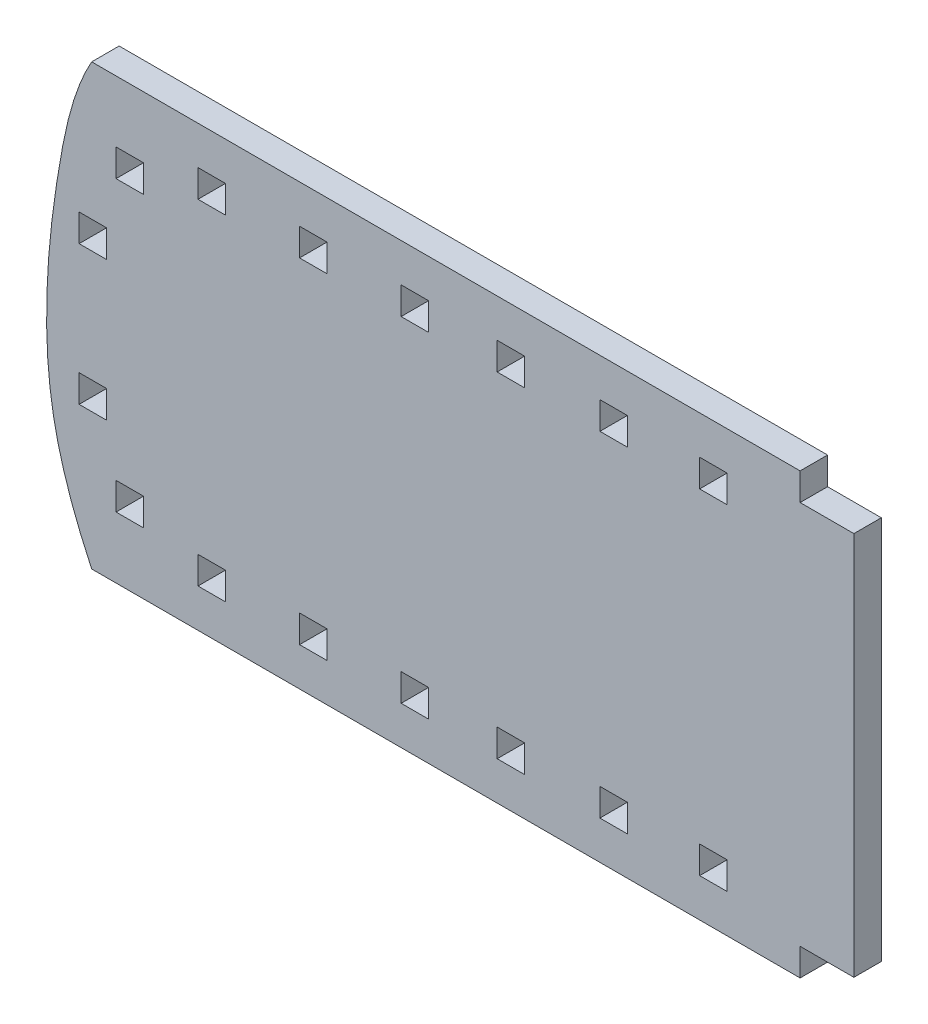
from build123d import *

# Parameters (mm, degrees)
BOSS_EXTRUDE1_DEPTH = 3.175
CUT_EXTRUDE1_DEPTH  = 3.175
SKETCH3_W           = 3.175
SKETCH3_H           = 3.175
CUT_EXTRUDE2_DEPTH  = 3.175
SKETCH4_W           = 9.525
SKETCH4_H           = 44.45
CUT_EXTRUDE3_DEPTH  = 3.175
CUT_EXTRUDE4_DEPTH  = 3.175


with BuildPart() as part:
    # Sketch1 → Boss-Extrude1 (new body)
    with BuildSketch(Plane.XY):
        with BuildLine():
            Line((47.738161277, 0), (129.678020066, 0))
            Line((129.678020066, 0), (129.678020066, -3.175))
            Line((129.678020066, -3.175), (145.421593995, -3.175))
            Line((145.421593995, -3.175), (145.421593995, -47.625))
            Line((145.421593995, -47.625), (129.678020066, -47.625))
            Line((129.678020066, -47.625), (129.678020066, -51.488987453))
            Line((129.678020066, -51.488987453), (47.738161277, -50.8))
            add(Edge.make_bspline(
                [(47.738161277, 0), (41.393133439, -1.711069928), (30.530442831, -9.367517151), (28.681444031, -25.622801065), (30.401296487, -42.131760993), (41.721917061, -48.493240739), (47.738161277, -50.8)],
                knots=[0, 0, 0, 0, 0.298782405, 0.512668788, 0.698134952, 1, 1, 1, 1], degree=3))
        make_face()
    extrude(amount=BOSS_EXTRUDE1_DEPTH)

    # Sketch2 → Cut-Extrude1 (cut)
    with BuildSketch(Plane.XY.offset(3.175)):
        with BuildLine():
            Line((47.738161277, 0), (25.94415126, 0))
            Line((25.94415126, 0), (25.94415126, -50.8))
            Line((25.94415126, -50.8), (47.738161277, -50.8))
            add(Edge.make_bspline(
                [(47.738161277, 0), (45.681525529, -3.647242432), (43.645083007, -12.887655636), (42.176101449, -25.699616702), (42.981732395, -39.048066027), (45.802728015, -46.725242417), (47.738161277, -50.8)],
                knots=[0, 0, 0, 0, 0.238683845, 0.536924902, 0.740325465, 1, 1, 1, 1], degree=3))
        make_face()
    extrude(amount=-CUT_EXTRUDE1_DEPTH, mode=Mode.SUBTRACT)

    # Sketch3 → Cut-Extrude2 (cut)
    with BuildSketch(Plane.XY.offset(3.175)):
        with Locations((61.621228186, -6.030517165)):
            Rectangle(SKETCH3_W, SKETCH3_H)
        with Locations((73.369830924, -6.030517165)):
            Rectangle(SKETCH3_W, SKETCH3_H)
        with Locations((85.118433661, -6.030517165)):
            Rectangle(SKETCH3_W, SKETCH3_H)
        with Locations((96.226203523, -6.030517165)):
            Rectangle(SKETCH3_W, SKETCH3_H)
        with Locations((108.110776123, -6.030517165)):
            Rectangle(SKETCH3_W, SKETCH3_H)
        with Locations((119.645767902, -6.030517165)):
            Rectangle(SKETCH3_W, SKETCH3_H)
        with Locations((52.144704899, -8.700654151)):
            Rectangle(SKETCH3_W, SKETCH3_H)
        with Locations((47.872485722, -17.351897985)):
            Rectangle(SKETCH3_W, SKETCH3_H)
        with Locations((47.872485722, -33.448102015)):
            Rectangle(SKETCH3_W, SKETCH3_H)
        with Locations((52.144704899, -42.099345849)):
            Rectangle(SKETCH3_W, SKETCH3_H)
        with Locations((61.621228186, -44.769482835)):
            Rectangle(SKETCH3_W, SKETCH3_H)
        with Locations((73.369830924, -44.769482835)):
            Rectangle(SKETCH3_W, SKETCH3_H)
        with Locations((85.118433661, -44.769482835)):
            Rectangle(SKETCH3_W, SKETCH3_H)
        with Locations((96.226203523, -44.769482835)):
            Rectangle(SKETCH3_W, SKETCH3_H)
        with Locations((108.110776123, -44.769482835)):
            Rectangle(SKETCH3_W, SKETCH3_H)
        with Locations((119.645767902, -44.769482835)):
            Rectangle(SKETCH3_W, SKETCH3_H)
    extrude(amount=-CUT_EXTRUDE2_DEPTH, mode=Mode.SUBTRACT)

    # Sketch4 → Cut-Extrude3 (cut)
    with BuildSketch(Plane.XY.offset(3.175)):
        with Locations((140.659093995, -25.4)):
            Rectangle(SKETCH4_W, SKETCH4_H)
    extrude(amount=-CUT_EXTRUDE3_DEPTH, mode=Mode.SUBTRACT)

    # Sketch5 → Cut-Extrude4 (cut)
    with BuildSketch(Plane.XY.offset(3.175)):
        Polygon((131.864975324, -55.496835694), (47.738161277, -50.8), (131.864975324, -50.8), align=None)
    extrude(amount=-CUT_EXTRUDE4_DEPTH, mode=Mode.SUBTRACT)


solid = part.part
